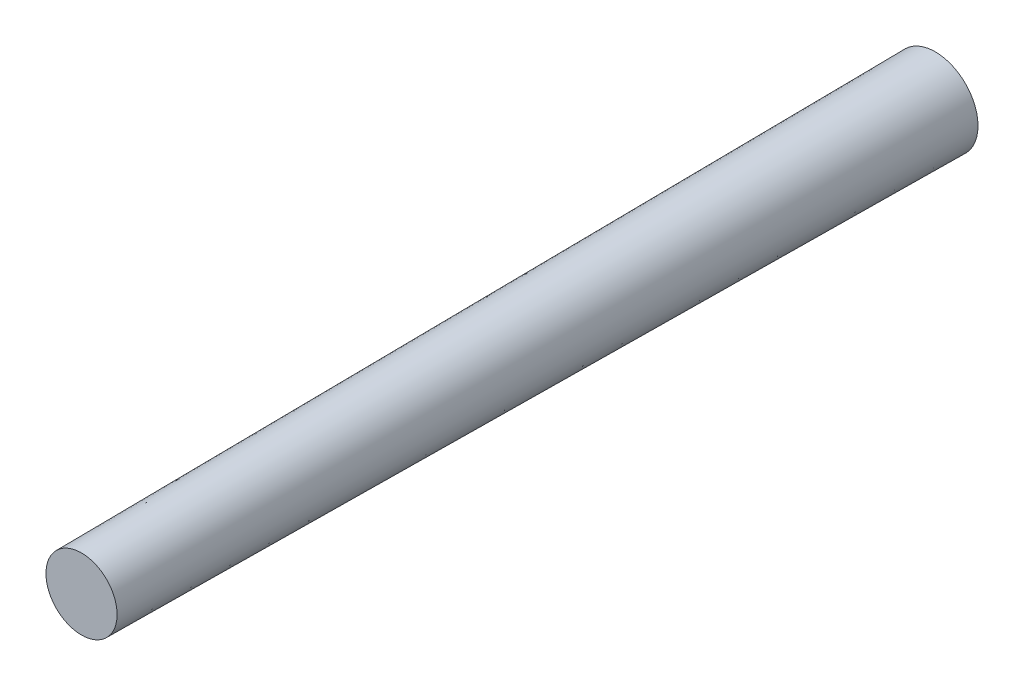
from build123d import *

# Parameters (mm, degrees)
SKETCH1_R           = 3
BOSS_EXTRUDE1_DEPTH = 60
BOSS_EXTRUDE1_TAPER = 0.477


with BuildPart() as part:
    # Sketch1 → Boss-Extrude1 (new body)
    with BuildSketch(Plane.XY):
        Circle(SKETCH1_R)
    extrude(amount=BOSS_EXTRUDE1_DEPTH, taper=BOSS_EXTRUDE1_TAPER)


solid = part.part
